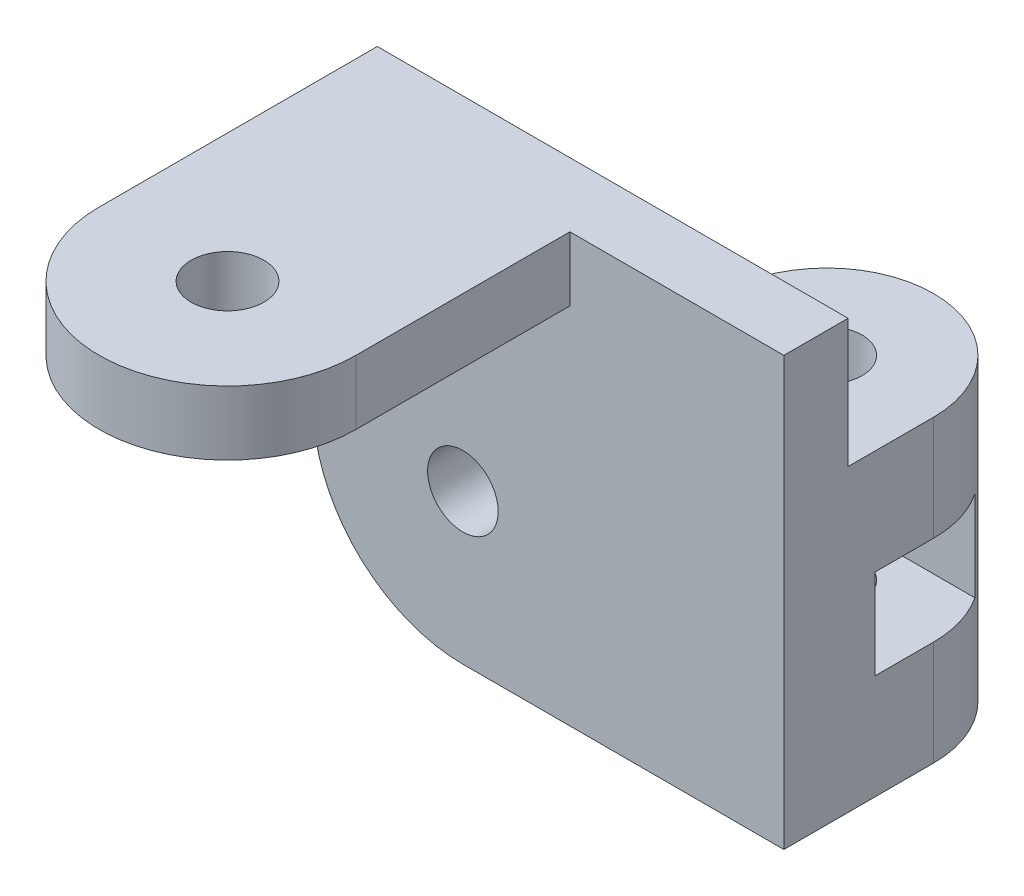
from build123d import *

# Parameters (mm, degrees)
ESBO_O1_R                = 1.65
RESSALTO_EXTRUS_O1_DEPTH = 3
ESBO_O3_R                = 1.65
RESSALTO_EXTRUS_O2_DEPTH = 14
ESBO_O4_W                = 5.5
ESBO_O4_H                = 4.2
CORTE_EXTRUS_O1_DEPTH    = 10
ESBO_O5_R                = 1.7
RESSALTO_EXTRUS_O3_DEPTH = 3


with BuildPart() as part:
    # Esboço1 → Ressalto-extrusão1 (new body)
    with BuildSketch(Plane.XY):
        with BuildLine():
            Line((-2.5, -7), (2.5, -7))
            Line((2.5, -7), (12.5, -7))
            Line((12.5, -7), (12.5, 13))
            Line((12.5, 13), (-9.5, 13))
            Line((-9.5, 13), (-9.5, 0))
            ThreePointArc((-9.5, 0), (-7.449747468, -4.949747468), (-2.5, -7))
        make_face()
        with Locations((-2.5, 0)):
            Circle(ESBO_O1_R, mode=Mode.SUBTRACT)
    extrude(amount=RESSALTO_EXTRUS_O1_DEPTH)

    # Esboço3 → Ressalto-extrusão2 (add)
    with BuildSketch(Plane(origin=(0, -7, 0), x_dir=(1, 0, 0), z_dir=(0, 1, 0))):
        with BuildLine():
            Line((2.5, 4), (2.5, 0))
            Line((2.5, 0), (12.5, 0))
            Line((12.5, 0), (12.5, 4))
            ThreePointArc((12.5, 4), (7.5, 9), (2.5, 4))
        make_face()
        with Locations((7.5, 4)):
            Circle(ESBO_O3_R, mode=Mode.SUBTRACT)
    extrude(amount=RESSALTO_EXTRUS_O2_DEPTH)

    # Esboço4 → Corte-extrusão1 (cut)
    with BuildSketch(Plane(origin=(12.5, 0, 0), x_dir=(0, 0, -1), z_dir=(1, 0, 0))):
        with Locations((4, 0)):
            Rectangle(ESBO_O4_W, ESBO_O4_H)
    extrude(amount=-CORTE_EXTRUS_O1_DEPTH, mode=Mode.SUBTRACT)

    # Esboço5 → Ressalto-extrusão3 (add)
    with BuildSketch(Plane(origin=(0, 13, 0), x_dir=(1, 0, 0), z_dir=(0, 1, 0))):
        with BuildLine():
            Line((2.5, 0), (2.5, -13))
            ThreePointArc((2.5, -13), (-3.5, -19), (-9.5, -13))
            Line((-9.5, -13), (-9.5, 0))
            Line((-9.5, 0), (2.5, 0))
        make_face()
        with Locations((-3.5, -13)):
            Circle(ESBO_O5_R, mode=Mode.SUBTRACT)
    extrude(amount=-RESSALTO_EXTRUS_O3_DEPTH)


solid = part.part
